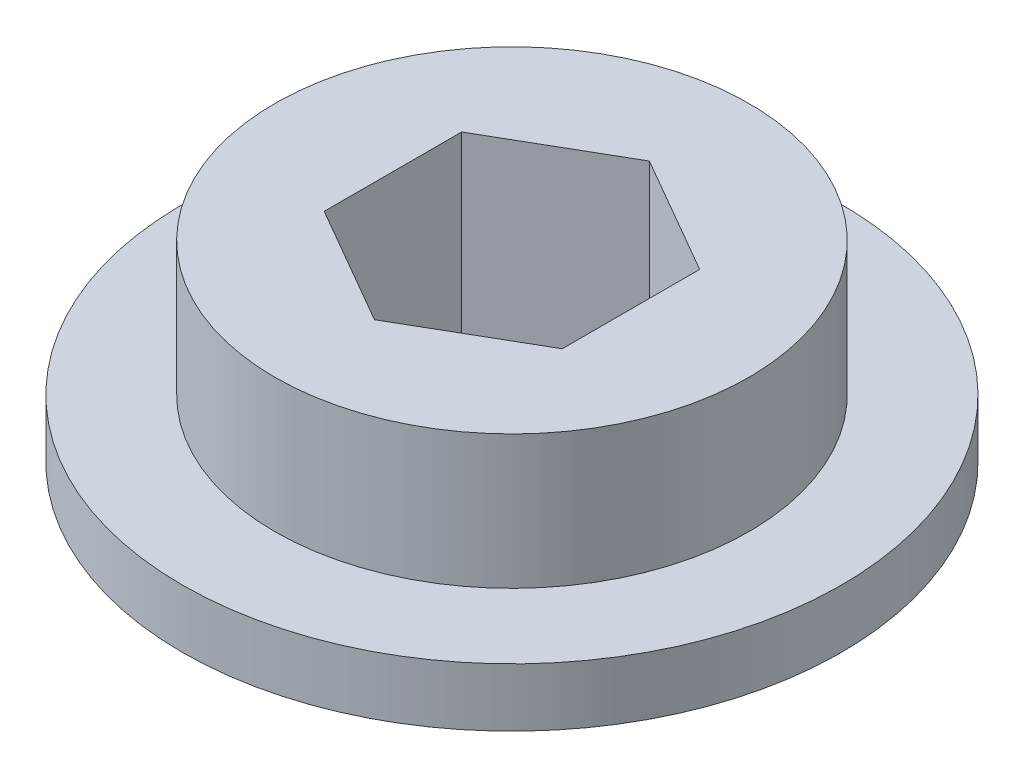
from build123d import *

# Parameters (mm, degrees)
SKETCH1_R           = 17.653
BOSS_EXTRUDE1_DEPTH = 10.287
SKETCH3_R           = 23.749
SKETCH3_R_2         = 12.7
CUT_EXTRUDE2_DEPTH  = 7.1628


with BuildPart() as part:
    # Sketch1 → Boss-Extrude1 (new body)
    with BuildSketch(Plane(origin=(0, 0, 0), x_dir=(1, 0, 0), z_dir=(0, 1, 0))):
        Circle(SKETCH1_R)
        Polygon((0, 7.361677812), (-6.3754, 3.680838906), (-6.3754, -3.680838906), (0, -7.361677812), (6.3754, -3.680838906), (6.3754, 3.680838906), align=None, mode=Mode.SUBTRACT)
    extrude(amount=BOSS_EXTRUDE1_DEPTH)

    # Sketch3 → Cut-Extrude2 (cut)
    with BuildSketch(Plane(origin=(0, 10.287, 0), x_dir=(1, 0, 0), z_dir=(0, 1, 0))):
        Circle(SKETCH3_R)
        Circle(SKETCH3_R_2, mode=Mode.SUBTRACT)
    extrude(amount=-CUT_EXTRUDE2_DEPTH, mode=Mode.SUBTRACT)


solid = part.part
